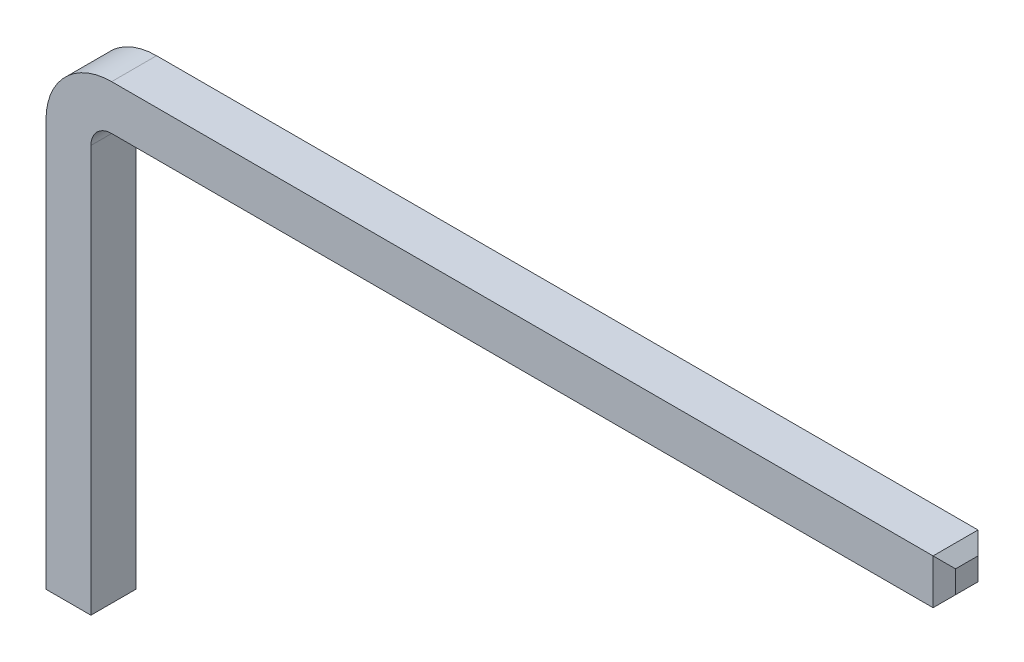
from build123d import *

# Parameters (mm, degrees)
BODY_DEPTH     = 0.65
CHAMFER_2_SIZE = 0.1625


with BuildPart() as part:
    # Sketch1 → Body (new body)
    with BuildSketch(Plane.XY):
        with BuildLine():
            Line((0.95, 7), (13, 7))
            Line((13, 7), (13, 6.35))
            Line((13, 6.35), (0.95, 6.35))
            ThreePointArc((0.95, 6.35), (0.737867966, 6.262132034), (0.65, 6.05))
            Line((0.65, 6.05), (0.65, 0))
            Line((0.65, 0), (0, 0))
            Line((0, 0), (0, 6.05))
            ThreePointArc((0, 6.05), (0.278248558, 6.721751442), (0.95, 7))
        make_face()
    extrude(amount=BODY_DEPTH)

    # Chamfer 2
    chamfer_2_edges = [part.edges().sort_by_distance(p)[0] for p in [
        (13, 7, 0.325),
        (13, 6.35, 0.325),
        (13, 6.675, 0),
        (13, 6.675, 0.65),
        (0.65, 0, 0.325),
        (0, 0, 0.325),
        (0.325, 0, 0),
        (0.325, 0, 0.65),
    ]]
    chamfer(chamfer_2_edges, length=CHAMFER_2_SIZE)


solid = part.part
